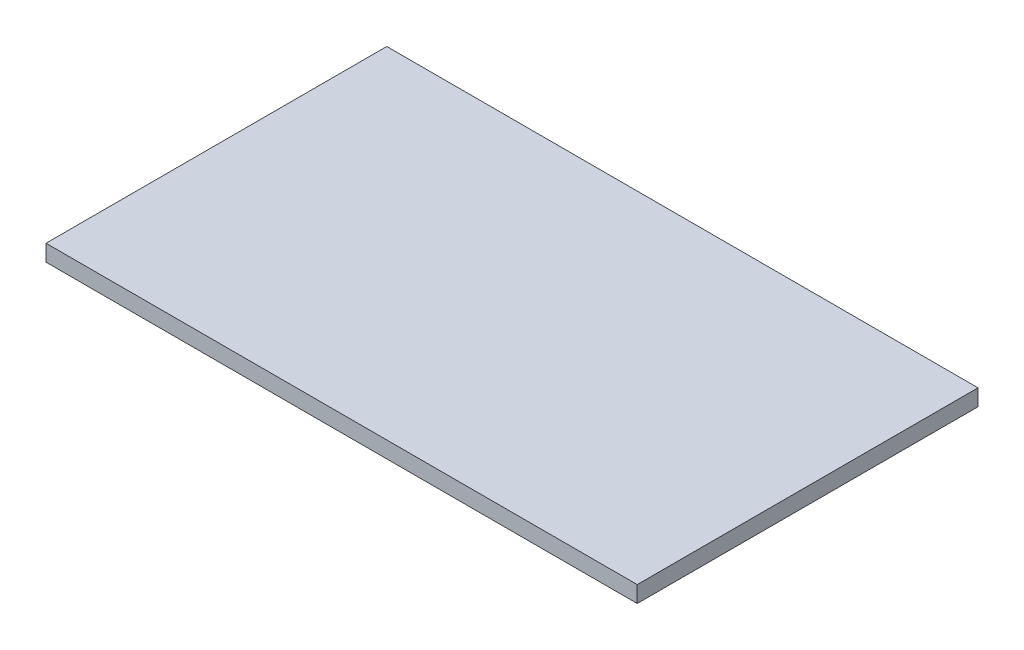
from build123d import *

# Parameters (mm, degrees)
SKETCH1_W           = 720
SKETCH1_H           = 415
BOSS_EXTRUDE1_DEPTH = 10


with BuildPart() as part:
    # Sketch1 → Boss-Extrude1 (new body, symmetric)
    with BuildSketch(Plane(origin=(0, 0, 0), x_dir=(1, 0, 0), z_dir=(0, 1, 0))):
        Rectangle(SKETCH1_W, SKETCH1_H)
    extrude(amount=BOSS_EXTRUDE1_DEPTH, both=True)


solid = part.part
